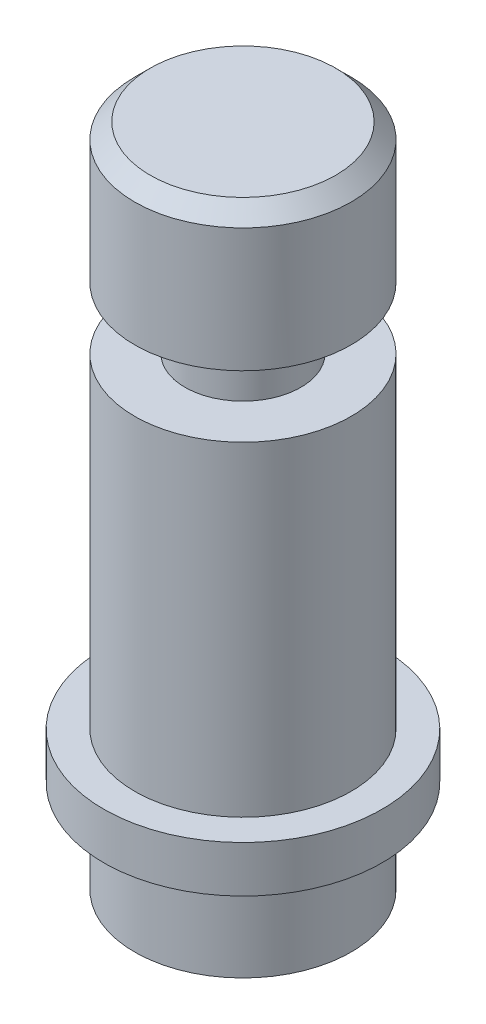
from build123d import *

# Parameters (mm, degrees)
CHAMFER1_SIZE = 1


with BuildPart() as part:
    # Sketch1 → Revolve1 (revolve)
    with BuildSketch(Plane.XY):
        Polygon((0, 0), (7, 0), (7, 6), (9, 6), (9, 9), (7, 9), (7, 30), (3.75, 30), (3.75, 34), (7, 34), (7, 43), (0, 43), align=None)
    revolve(axis=Axis((0, 43, 0), (0, -1, 0)))

    # Chamfer1
    chamfer1_edges = [part.edges().sort_by_distance(p)[0] for p in [
        (-7, 43, 0),
    ]]
    chamfer(chamfer1_edges, length=CHAMFER1_SIZE)


solid = part.part
